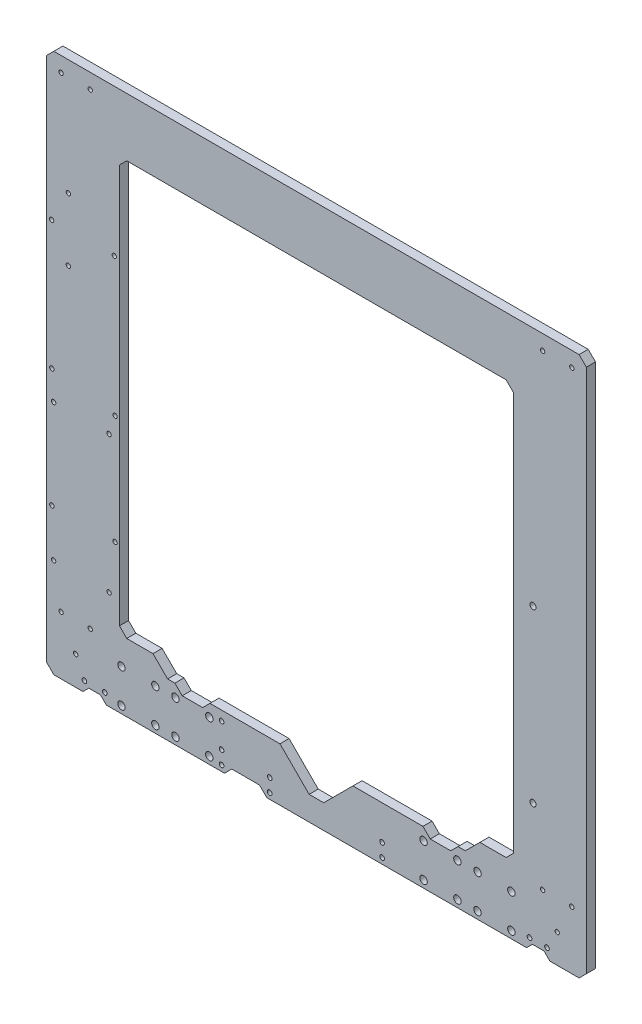
from build123d import *

# Parameters (mm, degrees)
SKETCH1_R           = 1.5
SKETCH1_R_2         = 1.6
SKETCH1_R_3         = 2.55
SKETCH1_R_4         = 2.1
BOSS_EXTRUDE1_DEPTH = 6.25


with BuildPart() as part:
    # Sketch1 → Boss-Extrude1 (new body)
    with BuildSketch(Plane.XY):
        Polygon((180, 196.75), (-180, 196.75), (-185, 191.75), (-185, -168.25), (-180, -173.25), (-160, -173.25), (-156, -169.25), (-148, -169.25), (-144, -173.25), (-63, -173.25), (-58, -168.25), (-39, -168.25), (-34, -173.25), (144, -173.25), (148, -169.25), (156, -169.25), (160, -173.25), (180, -173.25), (185, -168.25), (185, 191.75), align=None)
        with Locations(Location((165, -153.45, 0), (0, 0, 180))):  # turned: the seam where the file's is
            Circle(SKETCH1_R, mode=Mode.SUBTRACT)
        with Locations(Location((-155, 186.55, 0), (0, 0, 180))):  # turned: the seam where the file's is
            Circle(SKETCH1_R, mode=Mode.SUBTRACT)
        with Locations(Location((-175, -133.45, 0), (0, 0, 180))):  # turned: the seam where the file's is
            Circle(SKETCH1_R, mode=Mode.SUBTRACT)
        with Locations(Location((-65, -143.25, 0), (0, 0, 180))):  # turned: the seam where the file's is
            Circle(SKETCH1_R_2, mode=Mode.SUBTRACT)
        with Locations(Location((-175, 186.55, 0), (0, 0, 180))):  # turned: the seam where the file's is
            Circle(SKETCH1_R, mode=Mode.SUBTRACT)
        with Locations(Location((-180.1, -11.45, 0), (0, 0, 180))):  # turned: the seam where the file's is
            Circle(SKETCH1_R, mode=Mode.SUBTRACT)
        with Locations(Location((-181.5, 96.05, 0), (0, 0, 180))):  # turned: the seam where the file's is
            Circle(SKETCH1_R, mode=Mode.SUBTRACT)
        with Locations(Location((-181.3, 7.85, 0), (0, 0, 180))):  # turned: the seam where the file's is
            Circle(SKETCH1_R, mode=Mode.SUBTRACT)
        with Locations(Location((-138, 1.45, 0), (0, 0, 180))):  # turned: the seam where the file's is
            Circle(SKETCH1_R, mode=Mode.SUBTRACT)
        with Locations(Location((-138.5, 96.05, 0), (0, 0, 180))):  # turned: the seam where the file's is
            Circle(SKETCH1_R, mode=Mode.SUBTRACT)
        with Locations(Location((-165, -153.45, 0), (0, 0, 180))):  # turned: the seam where the file's is
            Circle(SKETCH1_R, mode=Mode.SUBTRACT)
        with Locations(Location((-181.3, -73.45, 0), (0, 0, 180))):  # turned: the seam where the file's is
            Circle(SKETCH1_R, mode=Mode.SUBTRACT)
        with Locations(Location((175, 186.55, 0), (0, 0, 180))):  # turned: the seam where the file's is
            Circle(SKETCH1_R, mode=Mode.SUBTRACT)
        with Locations(Location((-170, 74.55, 0), (0, 0, 180))):  # turned: the seam where the file's is
            Circle(SKETCH1_R, mode=Mode.SUBTRACT)
        with Locations(Location((-138, -73.45, 0), (0, 0, 180))):  # turned: the seam where the file's is
            Circle(SKETCH1_R, mode=Mode.SUBTRACT)
        with Locations(Location((155, -133.45, 0), (0, 0, 180))):  # turned: the seam where the file's is
            Circle(SKETCH1_R, mode=Mode.SUBTRACT)
        with Locations(Location((175, -133.45, 0), (0, 0, 180))):  # turned: the seam where the file's is
            Circle(SKETCH1_R, mode=Mode.SUBTRACT)
        with Locations(Location((-180.1, -105.45, 0), (0, 0, 180))):  # turned: the seam where the file's is
            Circle(SKETCH1_R, mode=Mode.SUBTRACT)
        with Locations(Location((155, 186.55, 0), (0, 0, 180))):  # turned: the seam where the file's is
            Circle(SKETCH1_R, mode=Mode.SUBTRACT)
        with Locations(Location((-170, 117.55, 0), (0, 0, 180))):  # turned: the seam where the file's is
            Circle(SKETCH1_R, mode=Mode.SUBTRACT)
        with Locations(Location((-159, -166.25, 0), (0, 0, 180))):  # turned: the seam where the file's is
            Circle(SKETCH1_R_2, mode=Mode.SUBTRACT)
        with Locations(Location((133.6, -168.35, 0), (0, 0, 180))):  # turned: the seam where the file's is
            Circle(SKETCH1_R_3, mode=Mode.SUBTRACT)
        with Locations(Location((-145, -166.25, 0), (0, 0, 180))):  # turned: the seam where the file's is
            Circle(SKETCH1_R_2, mode=Mode.SUBTRACT)
        with Locations(Location((96.6, -145.15, 0), (0, 0, 180))):  # turned: the seam where the file's is
            Circle(SKETCH1_R_3, mode=Mode.SUBTRACT)
        with Locations(Location((73.4, -168.35, 0), (0, 0, 180))):  # turned: the seam where the file's is
            Circle(SKETCH1_R_3, mode=Mode.SUBTRACT)
        with Locations(Location((-73.4, -168.35, 0), (0, 0, 180))):  # turned: the seam where the file's is
            Circle(SKETCH1_R_3, mode=Mode.SUBTRACT)
        with Locations(Location((96.6, -168.35, 0), (0, 0, 180))):  # turned: the seam where the file's is
            Circle(SKETCH1_R_3, mode=Mode.SUBTRACT)
        with Locations(Location((-73.4, -145.15, 0), (0, 0, 180))):  # turned: the seam where the file's is
            Circle(SKETCH1_R_3, mode=Mode.SUBTRACT)
        with Locations(Location((-110.4, -168.35, 0), (0, 0, 180))):  # turned: the seam where the file's is
            Circle(SKETCH1_R_3, mode=Mode.SUBTRACT)
        with Locations(Location((-133.6, -168.35, 0), (0, 0, 180))):  # turned: the seam where the file's is
            Circle(SKETCH1_R_3, mode=Mode.SUBTRACT)
        with Locations(Location((-110.4, -145.15, 0), (0, 0, 180))):  # turned: the seam where the file's is
            Circle(SKETCH1_R_3, mode=Mode.SUBTRACT)
        with Locations(Location((73.4, -145.15, 0), (0, 0, 180))):  # turned: the seam where the file's is
            Circle(SKETCH1_R_3, mode=Mode.SUBTRACT)
        with Locations(Location((146, -166.25, 0), (0, 0, 180))):  # turned: the seam where the file's is
            Circle(SKETCH1_R_2, mode=Mode.SUBTRACT)
        with Locations(Location((-133.6, -145.15, 0), (0, 0, 180))):  # turned: the seam where the file's is
            Circle(SKETCH1_R_3, mode=Mode.SUBTRACT)
        with Locations(Location((110.4, -145.15, 0), (0, 0, 180))):  # turned: the seam where the file's is
            Circle(SKETCH1_R_3, mode=Mode.SUBTRACT)
        with Locations(Location((-96.6, -145.15, 0), (0, 0, 180))):  # turned: the seam where the file's is
            Circle(SKETCH1_R_3, mode=Mode.SUBTRACT)
        with Locations(Location((110.4, -168.35, 0), (0, 0, 180))):  # turned: the seam where the file's is
            Circle(SKETCH1_R_3, mode=Mode.SUBTRACT)
        with Locations(Location((133.6, -145.15, 0), (0, 0, 180))):  # turned: the seam where the file's is
            Circle(SKETCH1_R_3, mode=Mode.SUBTRACT)
        with Locations(Location((-96.6, -168.35, 0), (0, 0, 180))):  # turned: the seam where the file's is
            Circle(SKETCH1_R_3, mode=Mode.SUBTRACT)
        with Locations(Location((158, -166.25, 0), (0, 0, 180))):  # turned: the seam where the file's is
            Circle(SKETCH1_R_2, mode=Mode.SUBTRACT)
        with Locations(Location((-65, -160.25, 0), (0, 0, 180))):  # turned: the seam where the file's is
            Circle(SKETCH1_R_2, mode=Mode.SUBTRACT)
        with Locations(Location((-65, -169.25, 0), (0, 0, 180))):  # turned: the seam where the file's is
            Circle(SKETCH1_R_2, mode=Mode.SUBTRACT)
        with Locations(Location((45, -160.25, 0), (0, 0, 180))):  # turned: the seam where the file's is
            Circle(SKETCH1_R_2, mode=Mode.SUBTRACT)
        with Locations(Location((148.4, 31.75, 0), (0, 0, 180))):  # turned: the seam where the file's is
            Circle(SKETCH1_R_4, mode=Mode.SUBTRACT)
        with Locations(Location((45, -169.25, 0), (0, 0, 180))):  # turned: the seam where the file's is
            Circle(SKETCH1_R_2, mode=Mode.SUBTRACT)
        with Locations(Location((148.4, -85.25, 0), (0, 0, 180))):  # turned: the seam where the file's is
            Circle(SKETCH1_R_4, mode=Mode.SUBTRACT)
        with Locations(Location((-32, -160.25, 0), (0, 0, 180))):  # turned: the seam where the file's is
            Circle(SKETCH1_R_2, mode=Mode.SUBTRACT)
        with Locations(Location((-32, -169.25, 0), (0, 0, 180))):  # turned: the seam where the file's is
            Circle(SKETCH1_R_2, mode=Mode.SUBTRACT)
        with Locations(Location((-142.1, -11.45, 0), (0, 0, 180))):  # turned: the seam where the file's is
            Circle(SKETCH1_R, mode=Mode.SUBTRACT)
        with Locations(Location((-155, -133.45, 0), (0, 0, 180))):  # turned: the seam where the file's is
            Circle(SKETCH1_R, mode=Mode.SUBTRACT)
        with Locations(Location((-142.1, -105.45, 0), (0, 0, 180))):  # turned: the seam where the file's is
            Circle(SKETCH1_R, mode=Mode.SUBTRACT)
        Polygon((-92, -141.75), (-97, -136.75), (-102, -136.75), (-112, -126.75), (-130, -126.75), (-135, -121.75), (-135, 151.75), (-130, 156.75), (130, 156.75), (135, 151.75), (135, -121.75), (130, -126.75), (112, -126.75), (102, -136.75), (97, -136.75), (92, -141.75), (78, -141.75), (73, -136.75), (25, -136.75), (5, -156.75), (-5, -156.75), (-25, -136.75), (-73, -136.75), (-78, -141.75), align=None, mode=Mode.SUBTRACT)
    extrude(amount=-BOSS_EXTRUDE1_DEPTH)


solid = part.part
